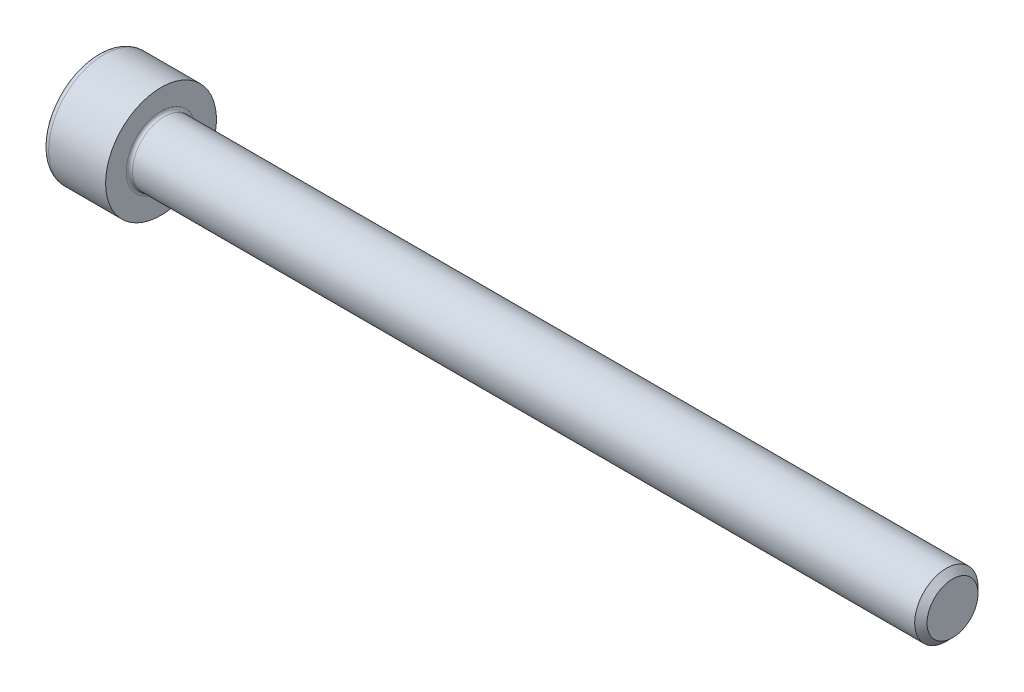
from build123d import *

# Parameters (mm, degrees)
FILLET1_R   = 0.2
FILLET2_R   = 0.4
HEX_2_DEPTH = 2


with BuildPart() as part:
    # BodySke → Base-Revolve (revolve)
    with BuildSketch(Plane.XY):
        Polygon((0, 0), (0, 3.5), (4, 3.5), (4, 2), (53.61, 2), (54, 1.61), (54, 0), align=None)
    revolve(axis=Axis((-31.75, 0, 0), (1, 0, 0)))

    # Fillet1
    fillet1_edges = [part.edges().sort_by_distance(p)[0] for p in [
        (4, -2, 0),
    ]]
    fillet(fillet1_edges, radius=FILLET1_R)

    # Fillet2
    fillet2_edges = [part.edges().sort_by_distance(p)[0] for p in [
        (0, -3.5, 0),
    ]]
    fillet(fillet2_edges, radius=FILLET2_R)

    # Sketch2 → Hex-PreBroach (revolve, cut)
    with BuildSketch(Plane.XY):
        Polygon((0, 1.51), (2, 1.51), (2.871798906, 0), (0, 0), align=None)
    revolve(axis=Axis((0, 0, 0), (1, 0, 0)), mode=Mode.SUBTRACT)

    # Sketch3 → Hex 2 (cut)
    with BuildSketch(Plane(origin=(0, 0, 0), x_dir=(0, 0.5, 0.866025404), z_dir=(-1, 0, 0))):
        Polygon((0.871798906, 1.51), (-0.871798906, 1.51), (-1.743597813, 0), (-0.871798906, -1.51), (0.871798906, -1.51), (1.743597813, 0), align=None)
    extrude(amount=-HEX_2_DEPTH, mode=Mode.SUBTRACT)


solid = part.part
